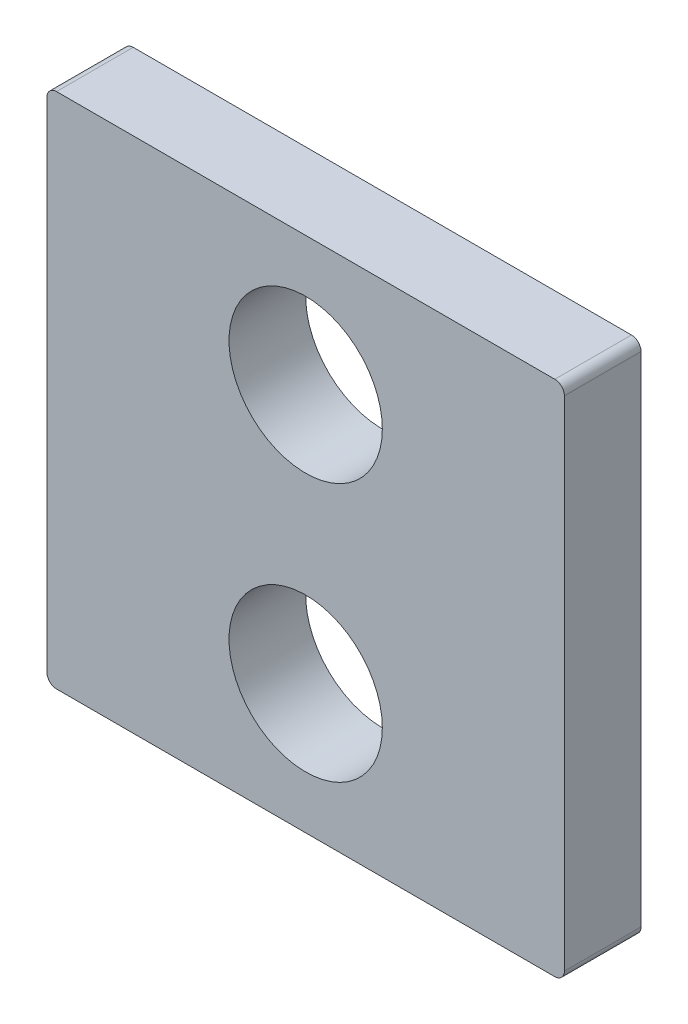
from build123d import *

# Parameters (mm, degrees)
BOSS_EXTRUDE1_DEPTH        = 12.7
F_1_1_DIAMETER_HOLE1_D     = 25.4
F_1_1_DIAMETER_HOLE1_DEPTH = 12.7


with BuildPart() as part:
    # Sketch1 → Boss-Extrude1 (new body)
    with BuildSketch(Plane.XY):
        with BuildLine():
            Line((150.064965963, 69.04320968), (150.064965963, -13.50679032))
            ThreePointArc((150.064965963, -13.50679032), (150.529933948, -14.629322335), (151.652465963, -15.09429032))
            Line((151.652465963, -15.09429032), (234.202465963, -15.09429032))
            ThreePointArc((234.202465963, -15.09429032), (235.324997978, -14.629322335), (235.789965963, -13.50679032))
            Line((235.789965963, -13.50679032), (235.789965963, 69.04320968))
            ThreePointArc((235.789965963, 69.04320968), (235.324997978, 70.165741695), (234.202465963, 70.63070968))
            Line((234.202465963, 70.63070968), (151.652465963, 70.63070968))
            ThreePointArc((151.652465963, 70.63070968), (150.529933948, 70.165741695), (150.064965963, 69.04320968))
        make_face()
    extrude(amount=-BOSS_EXTRUDE1_DEPTH)

    # 1 (1) Diameter Hole1
    with Locations(Plane.XY):
        with Locations((192.927465963, 6.33695968), (192.927465963, 49.19945968)):
            Hole(F_1_1_DIAMETER_HOLE1_D / 2, depth=F_1_1_DIAMETER_HOLE1_DEPTH)


solid = part.part
